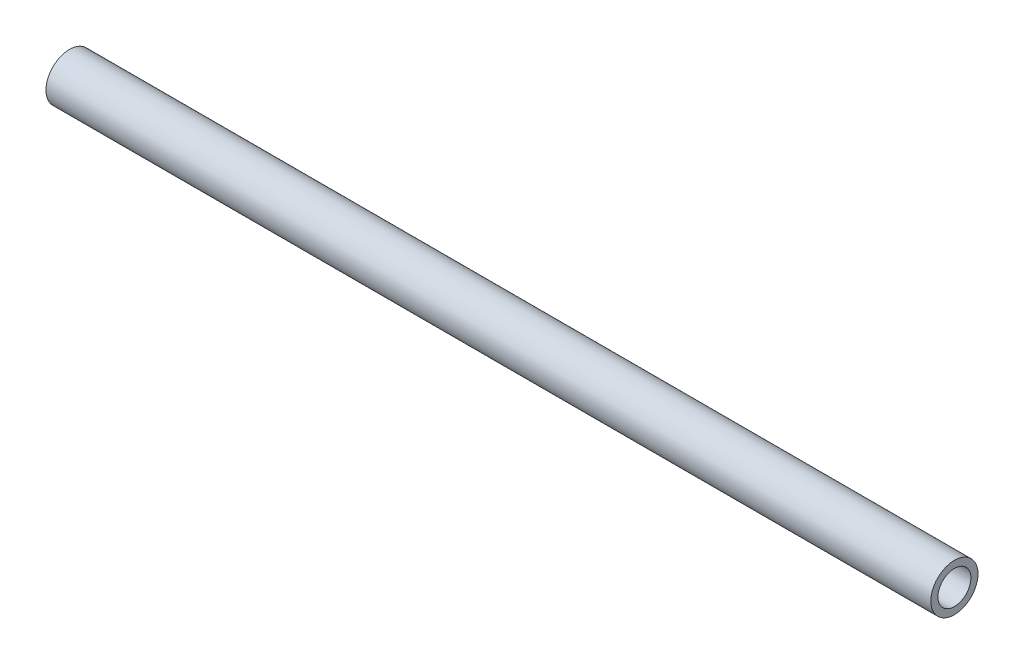
from build123d import *

# Parameters (mm, degrees)
SWEEP_THIN1_PROFILE_R   = 10
SWEEP_THIN1_PROFILE_R_2 = 7


with BuildPart() as part:
    # Sweep-Thin1: sweep along a path in Sketch1
    with BuildLine(Plane(origin=(0, 0, 0), x_dir=(1, 0, 0), z_dir=(0, 1, 0))) as sweep_thin1_path:
        Line((0, 0), (375.5, 0))
    # Sweep-Thin1 profile (on start of the path) → Sweep-Thin1 (sweep)
    with BuildSketch(Plane(origin=(0, 0, 0), x_dir=(0, 0, 1), z_dir=(1, 0, 0))):
        Circle(SWEEP_THIN1_PROFILE_R)
        Circle(SWEEP_THIN1_PROFILE_R_2, mode=Mode.SUBTRACT)
    sweep(path=sweep_thin1_path.line)


solid = part.part
